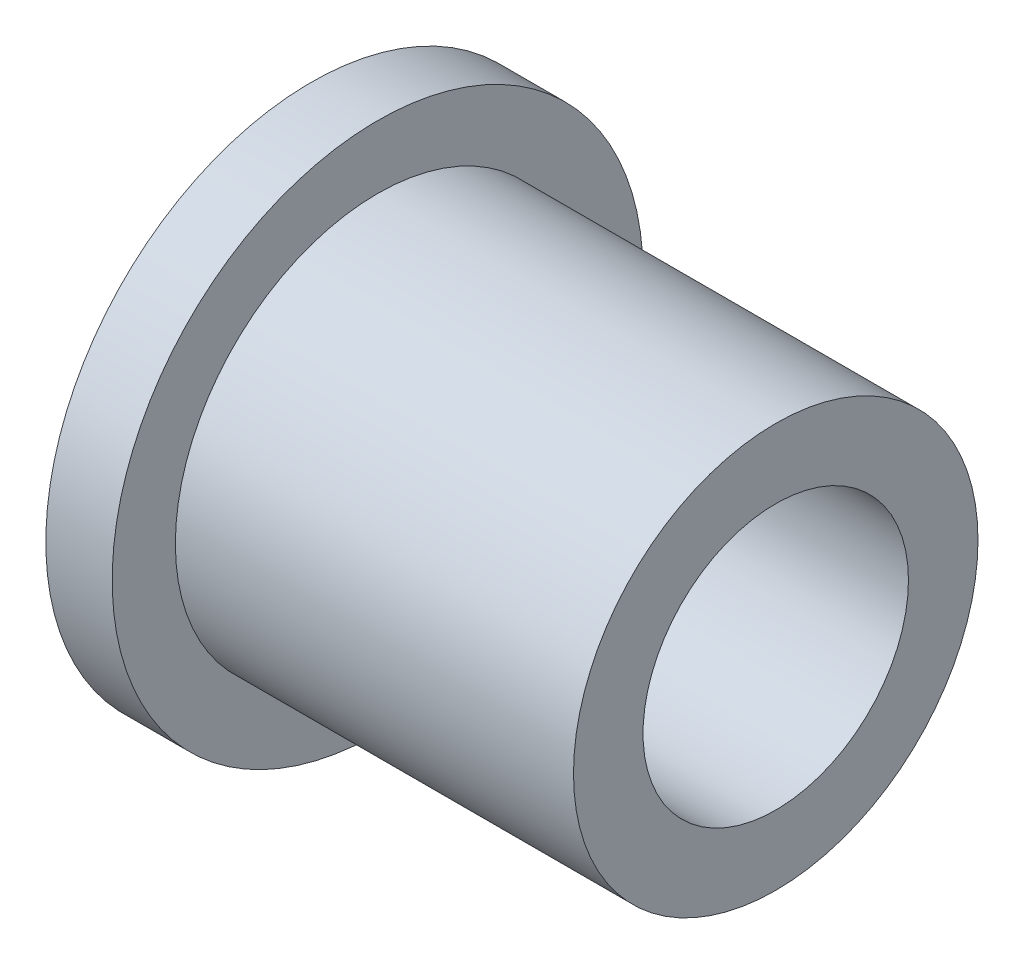
from build123d import *

# Parameters (mm, degrees)
SKETCH1_R           = 6.35
SKETCH1_R_2         = 3.175
BOSS_EXTRUDE1_DEPTH = 1.5875
SKETCH2_R           = 4.8387
SKETCH2_R_2         = 3.175
BOSS_EXTRUDE2_DEPTH = 9.525


with BuildPart() as part:
    # Sketch1 → Boss-Extrude1 (new body)
    with BuildSketch(Plane(origin=(0, 0, 0), x_dir=(0, 0, -1), z_dir=(1, 0, 0))):
        Circle(SKETCH1_R)
        Circle(SKETCH1_R_2, mode=Mode.SUBTRACT)
    extrude(amount=BOSS_EXTRUDE1_DEPTH)

    # Sketch2 → Boss-Extrude2 (add)
    with BuildSketch(Plane(origin=(1.5875, 0, 0), x_dir=(0, 0, -1), z_dir=(1, 0, 0))):
        Circle(SKETCH2_R)
        Circle(SKETCH2_R_2, mode=Mode.SUBTRACT)
    extrude(amount=BOSS_EXTRUDE2_DEPTH)


solid = part.part
